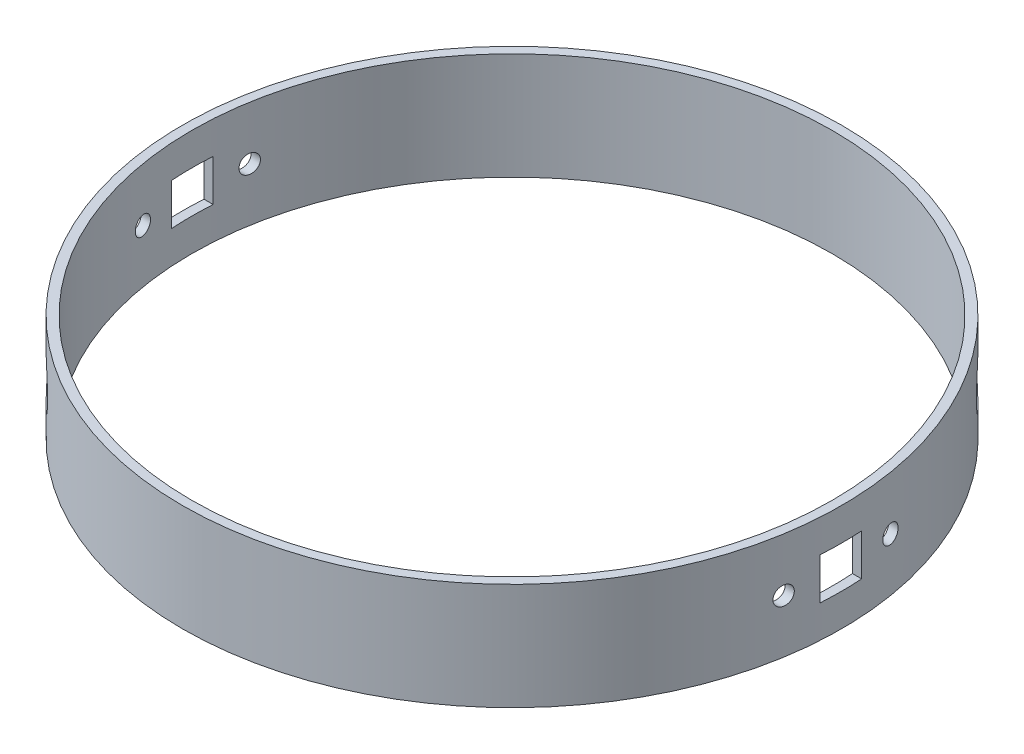
from build123d import *

# Parameters (mm, degrees)
SKETCH1_R                                    = 78.359
SKETCH1_R_2                                  = 76.1746
BOSS_EXTRUDE1_DEPTH                          = 25.4
SKETCH2_W                                    = 9.906
SKETCH2_H                                    = 9.906
SKETCH2_R                                    = 2.18313
CUT_EXTRUDE1_DEPTH                           = 114.690042493
MIRROR2_AT_THE_SECOND_PLANE_COPY_1_SKETC_R   = 78.359
MIRROR2_AT_THE_SECOND_PLANE_COPY_1_SKETC_R_2 = 76.1746
MIRROR2_AT_THE_SECOND_PLANE_COPY_1_DEPTH     = 25.4
MIRROR2_AT_THE_SECOND_PLANE_COPY_2_SKETC_W   = 9.906
MIRROR2_AT_THE_SECOND_PLANE_COPY_2_SKETC_H   = 9.906
MIRROR2_AT_THE_SECOND_PLANE_COPY_2_SKETC_R   = 2.18313
MIRROR2_AT_THE_SECOND_PLANE_COPY_2_DEPTH     = 114.690042493
CUT_EXTRUDE2_DEPTH                           = 114.690042653
CUT_EXTRUDE2_DEPTH_BACK                      = 114.690042653
SKETCH3_R                                    = 6.35


with BuildPart() as part:
    # Sketch1 → Boss-Extrude1 (new body)
    with BuildSketch(Plane(origin=(0, 0, 0), x_dir=(1, 0, 0), z_dir=(0, 1, 0))):
        Circle(SKETCH1_R)
        Circle(SKETCH1_R_2, mode=Mode.SUBTRACT)
    boss_extrude1 = extrude(amount=BOSS_EXTRUDE1_DEPTH)

    # Sketch2 → Cut-Extrude1 (cut, symmetric)
    with BuildSketch(Plane(origin=(0, 0, 0), x_dir=(0, 0, -1), z_dir=(1, 0, 0))):
        with Locations((0, 12.7)):
            Rectangle(SKETCH2_W, SKETCH2_H)
        with Locations((-12.7, 12.7)):
            Circle(SKETCH2_R)
        with Locations((12.7, 12.7)):
            Circle(SKETCH2_R)
    cut_extrude1 = extrude(amount=CUT_EXTRUDE1_DEPTH, both=True, mode=Mode.SUBTRACT)

    # Mirror2: Boss-Extrude1, Cut-Extrude1 across plane
    add(boss_extrude1.mirror(Plane(origin=(0, 0, 0), x_dir=(0, 0, 1), z_dir=(1, 0, 0))))
    add(cut_extrude1.mirror(Plane(origin=(0, 0, 0), x_dir=(0, 0, 1), z_dir=(1, 0, 0))), mode=Mode.SUBTRACT)

    # Mirror2 at the second plane: Boss-Extrude1, Cut-Extrude1 across plane
    add(boss_extrude1.mirror(Plane.ZX.offset(12.7)))
    add(cut_extrude1.mirror(Plane.ZX.offset(12.7)), mode=Mode.SUBTRACT)

    # Mirror2 at the second plane copy 1 sketc → Mirror2 at the second plane copy 1 (add)
    with BuildSketch(Plane(origin=(0, 25.4, 0), x_dir=(-1, 0, 0), z_dir=(0, -1, 0))):
        Circle(MIRROR2_AT_THE_SECOND_PLANE_COPY_1_SKETC_R)
        Circle(MIRROR2_AT_THE_SECOND_PLANE_COPY_1_SKETC_R_2, mode=Mode.SUBTRACT)
    extrude(amount=MIRROR2_AT_THE_SECOND_PLANE_COPY_1_DEPTH)

    # Mirror2 at the second plane copy 2 sketc → Mirror2 at the second plane copy 2 (cut, symmetric)
    with BuildSketch(Plane(origin=(0, 25.4, 0), x_dir=(0, 0, -1), z_dir=(-1, 0, 0))):
        with Locations((0, 12.7)):
            Rectangle(MIRROR2_AT_THE_SECOND_PLANE_COPY_2_SKETC_W, MIRROR2_AT_THE_SECOND_PLANE_COPY_2_SKETC_H)
        with Locations((-12.7, 12.7)):
            Circle(MIRROR2_AT_THE_SECOND_PLANE_COPY_2_SKETC_R)
        with Locations((12.7, 12.7)):
            Circle(MIRROR2_AT_THE_SECOND_PLANE_COPY_2_SKETC_R)
    extrude(amount=MIRROR2_AT_THE_SECOND_PLANE_COPY_2_DEPTH, both=True, mode=Mode.SUBTRACT)

    # Sketch3 → Cut-Extrude2 (cut, two sides: drawn at the far end of the back side and taken through both)
    with BuildSketch(Plane(origin=(0, 0, 0), x_dir=(-0.7071067811865477, 0, -0.7071067811865475), z_dir=(0.7071067811865475, 0, -0.7071067811865477)).offset(-CUT_EXTRUDE2_DEPTH_BACK)):
        with Locations((0, 12.7)):
            Circle(SKETCH3_R)
    extrude(amount=CUT_EXTRUDE2_DEPTH + CUT_EXTRUDE2_DEPTH_BACK, mode=Mode.SUBTRACT)


solid = part.part
